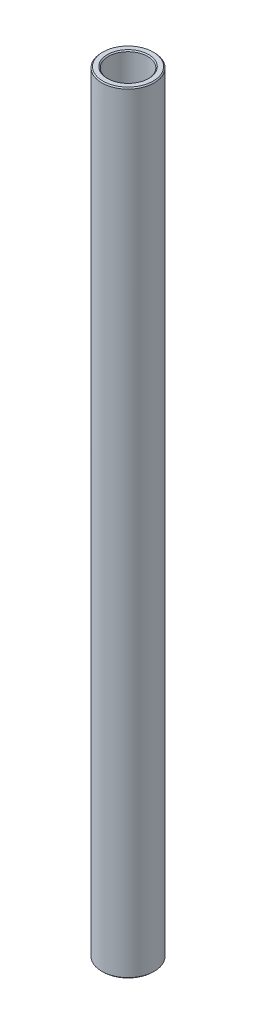
from build123d import *

# Parameters (mm, degrees)
SKETCH1_W     = 1.5875
SKETCH1_H     = 186.902515209
CHAMFER1_SIZE = 0.254


with BuildPart() as part:
    # Sketch1 → Revolve1 (revolve)
    with BuildSketch(Plane.XY):
        with Locations((5.55625, 153.610622799)):
            Rectangle(SKETCH1_W, SKETCH1_H)
    revolve(axis=Axis((0, 50.634365194, 0), (0, 1, 0)))

    # Chamfer1
    chamfer1_edges = [part.edges().sort_by_distance(p)[0] for p in [
        (-6.35, 60.159365194, 0),
        (-6.350000001, 247.061880403, 0),
        (-4.762500001, 247.061880403, 0),
        (-4.7625, 60.159365194, 0),
    ]]
    chamfer(chamfer1_edges, length=CHAMFER1_SIZE)


solid = part.part
